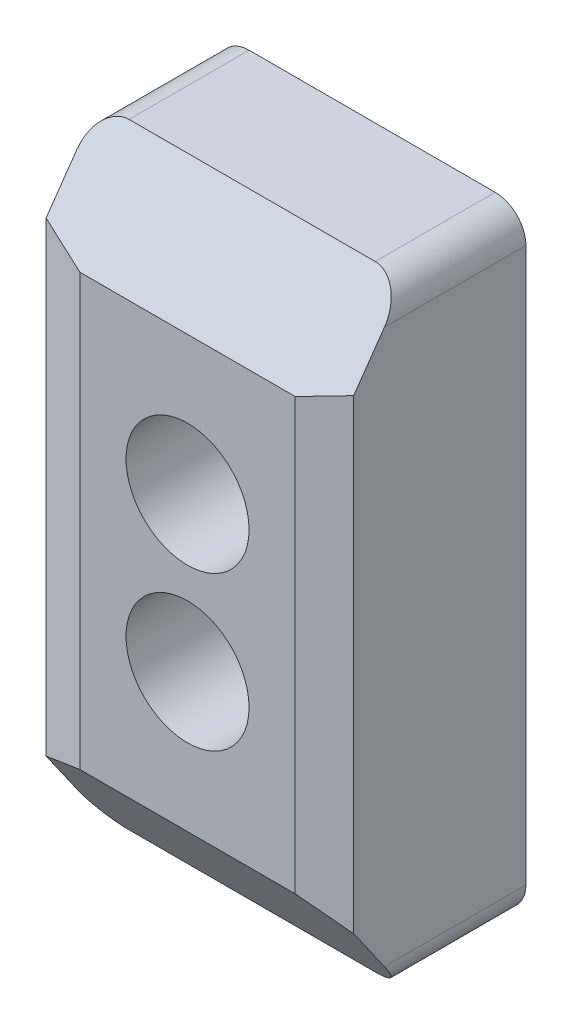
from build123d import *

# Parameters (mm, degrees)
SKETCH1_W           = 20
SKETCH1_H           = 40
SKETCH1_R           = 2.15
BOSS_EXTRUDE1_DEPTH = 12
CHAMFER1_SIZE       = 3
CHAMFER1_SIZE2      = 0.803847577
CHAMFER2_SIZE       = 6
CHAMFER2_SIZE2      = 4.201245229
SKETCH2_R           = 4
CUT_EXTRUDE1_DEPTH  = 11
FILLET1_R           = 2


with BuildPart() as part:
    # Sketch1 → Boss-Extrude1 (new body)
    with BuildSketch(Plane.XY):
        Rectangle(SKETCH1_W, SKETCH1_H)
        with Locations((0, -5)):
            Circle(SKETCH1_R, mode=Mode.SUBTRACT)
        with Locations((0, 5)):
            Circle(SKETCH1_R, mode=Mode.SUBTRACT)
    extrude(amount=BOSS_EXTRUDE1_DEPTH)

    # Chamfer1
    chamfer1_edges = [part.edges().sort_by_distance(p)[0] for p in [
        (-10, 0, 12),
        (10, 0, 12),
    ]]
    chamfer1_side = [part.faces().sort_by_distance(p)[0] for p in [
        (0, 0, 12),
    ]]
    chamfer(chamfer1_edges, length=CHAMFER1_SIZE, length2=CHAMFER1_SIZE2, reference=chamfer1_side[0])

    # Chamfer2
    chamfer2_edges = [part.edges().sort_by_distance(p)[0] for p in [
        (0, -20, 12),
        (0, 20, 12),
    ]]
    chamfer2_side = [part.faces().sort_by_distance(p)[0] for p in [
        (0, 0, 12),
    ]]
    chamfer(chamfer2_edges, length=CHAMFER2_SIZE, length2=CHAMFER2_SIZE2, reference=chamfer2_side[0])

    # Sketch2 → Cut-Extrude1 (cut)
    with BuildSketch(Plane.XY.offset(12)):
        with Locations((0, 5)):
            Circle(SKETCH2_R)
        with Locations((0, -5)):
            Circle(SKETCH2_R)
    extrude(amount=-CUT_EXTRUDE1_DEPTH, mode=Mode.SUBTRACT)

    # Fillet1
    fillet1_edges = [part.edges().sort_by_distance(p)[0] for p in [
        (10, 20, 3.899377385),
        (10, -20, 3.899377385),
        (-10, -20, 3.899377385),
        (-10, 20, 3.899377385),
    ]]
    fillet(fillet1_edges, radius=FILLET1_R)


solid = part.part
